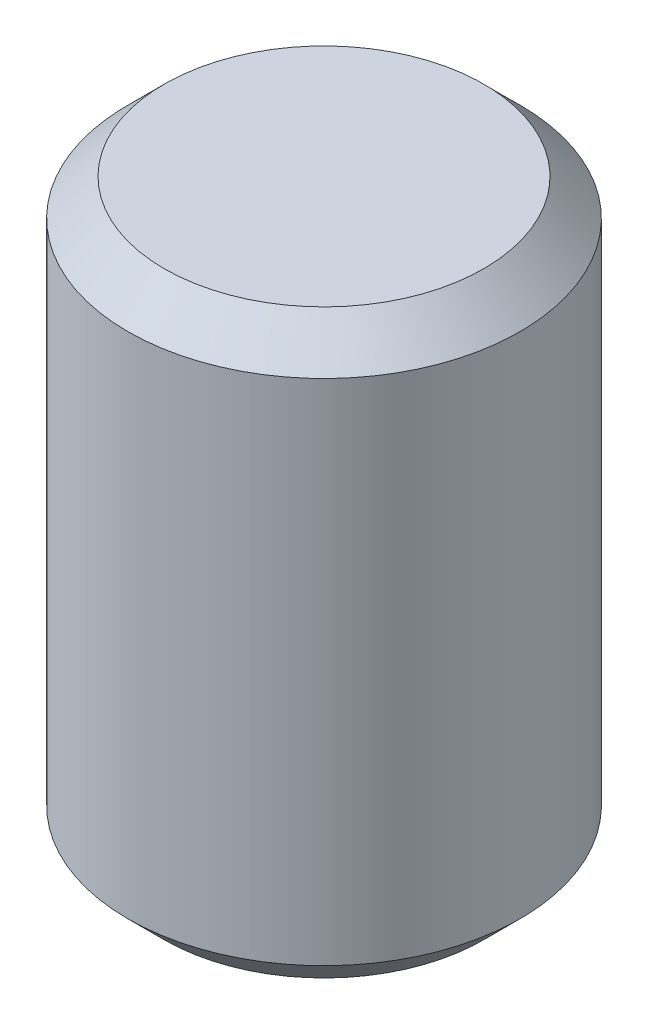
from build123d import *

# Parameters (mm, degrees)
SKETCH1_R           = 1.35
BOSS_EXTRUDE1_DEPTH = 4
CHAMFER1_SIZE       = 0.25


with BuildPart() as part:
    # Sketch1 → Boss-Extrude1 (new body)
    with BuildSketch(Plane(origin=(0, 0, 0), x_dir=(1, 0, 0), z_dir=(0, 1, 0))):
        Circle(SKETCH1_R)
    extrude(amount=BOSS_EXTRUDE1_DEPTH)

    # Chamfer1
    chamfer1_edges = [part.edges().sort_by_distance(p)[0] for p in [
        (-1.35, 0, 0),
        (-1.35, 4, 0),
    ]]
    chamfer(chamfer1_edges, length=CHAMFER1_SIZE)


solid = part.part
